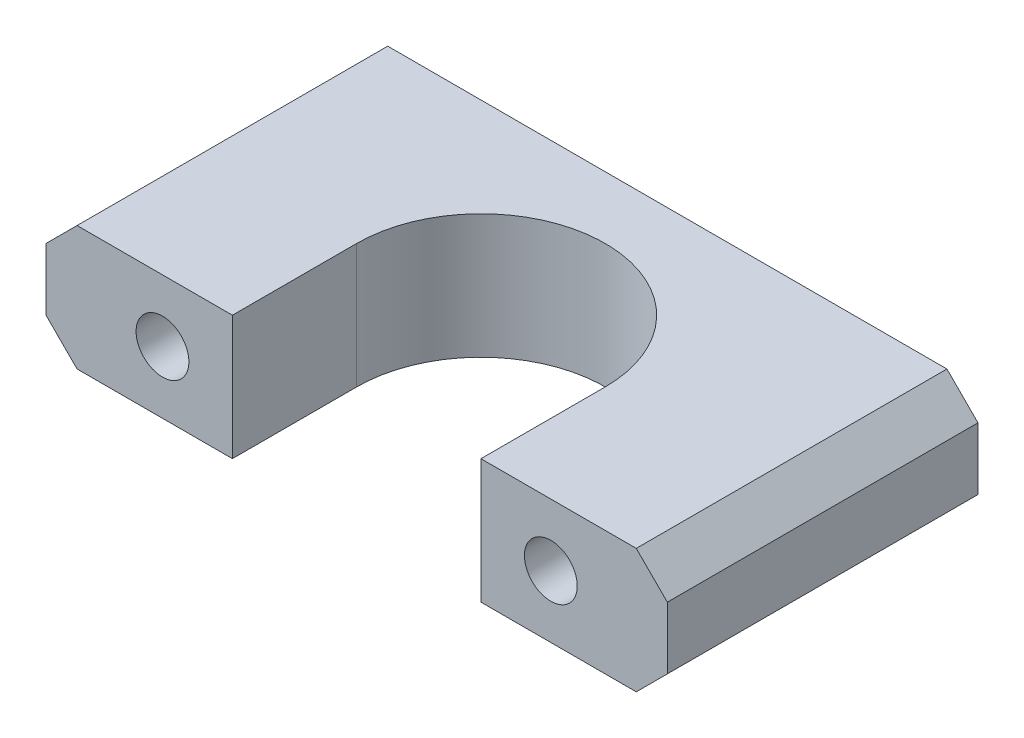
from build123d import *

# Parameters (mm, degrees)
SKETCH2_W           = 40
SKETCH2_H           = 20
BOSS_EXTRUDE1_DEPTH = 8
CUT_EXTRUDE1_DEPTH  = 9
SKETCH4_R           = 1.7
CUT_EXTRUDE2_DEPTH  = 21
CHAMFER1_SIZE       = 2


with BuildPart() as part:
    # Sketch2 → Boss-Extrude1 (new body)
    with BuildSketch(Plane(origin=(0, 0, 0), x_dir=(1, 0, 0), z_dir=(0, 1, 0))):
        with Locations((20, 10)):
            Rectangle(SKETCH2_W, SKETCH2_H)
    extrude(amount=BOSS_EXTRUDE1_DEPTH)

    # Sketch3 → Cut-Extrude1 (cut, through all)
    with BuildSketch(Plane.XZ):
        with BuildLine():
            Line((12, -8), (12, 0))
            Line((12, 0), (28, 0))
            Line((28, 0), (28, -8))
            ThreePointArc((28, -8), (20, -16), (12, -8))
        make_face()
    extrude(amount=-CUT_EXTRUDE1_DEPTH, mode=Mode.SUBTRACT)

    # Sketch4 → Cut-Extrude2 (cut, through all)
    with BuildSketch(Plane.XY):
        with Locations((7.5, 4)):
            Circle(SKETCH4_R)
        with Locations((32.5, 4)):
            Circle(SKETCH4_R)
    extrude(amount=-CUT_EXTRUDE2_DEPTH, mode=Mode.SUBTRACT)

    # Chamfer1
    chamfer1_edges = [part.edges().sort_by_distance(p)[0] for p in [
        (40, 8, -10),
        (0, 8, -10),
        (40, 0, -10),
        (0, 0, -10),
    ]]
    chamfer(chamfer1_edges, length=CHAMFER1_SIZE)


solid = part.part
